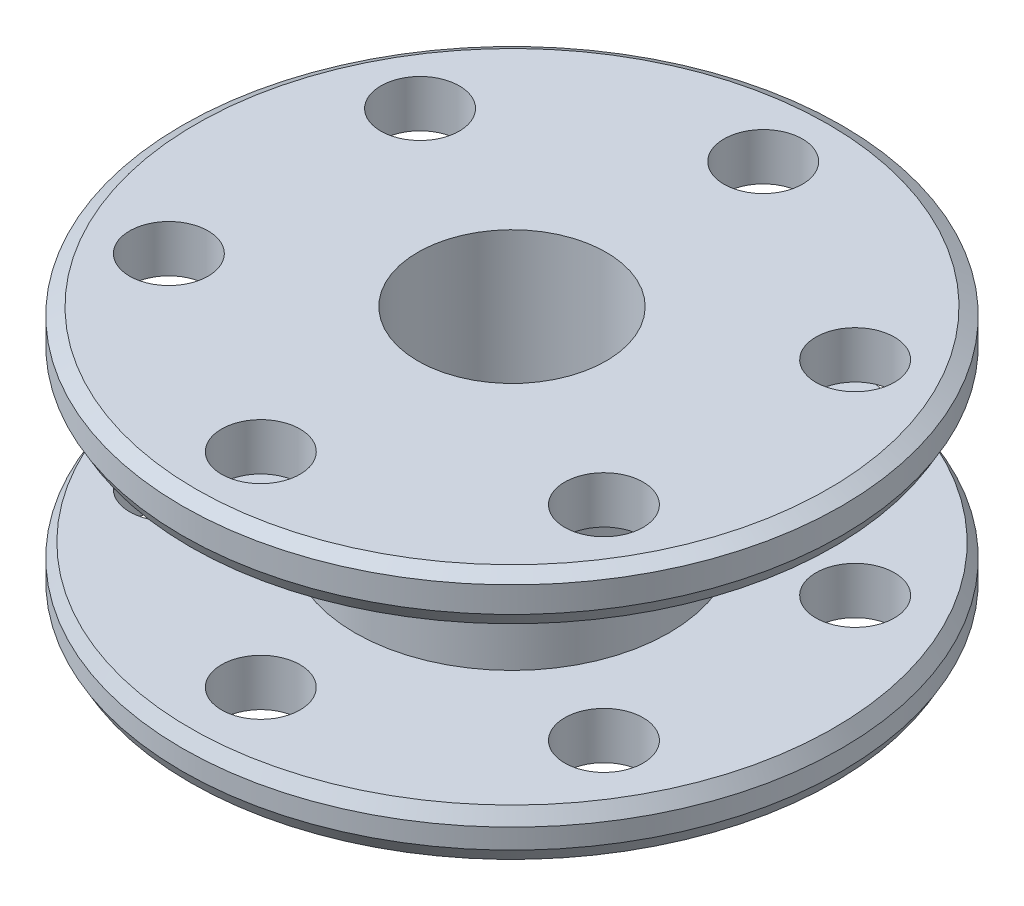
from build123d import *

# Parameters (mm, degrees)
SKETCH1_R             = 21
SKETCH1_R_2           = 6
SKETCH1_R_3           = 2.5
BOSS_EXTRUDE1_DEPTH   = 16
SKETCH2_W             = 19.188769359
SKETCH2_H             = 10
CHAMFER1_SIZE         = 0.5
CHAMFER1_SIZE2        = 0.866025404
CHAMFER1_PART_2_SIZE  = 0.5
CHAMFER1_PART_2_SIZE2 = 0.866025404
CHAMFER1_PART_3_SIZE  = 0.5
CHAMFER1_PART_3_SIZE2 = 0.866025404
CHAMFER1_PART_4_SIZE  = 0.5
CHAMFER1_PART_4_SIZE2 = 0.866025404


with BuildPart() as part:
    # Sketch1 → Boss-Extrude1 (new body)
    with BuildSketch(Plane(origin=(0, 0, 0), x_dir=(1, 0, 0), z_dir=(0, 1, 0))):
        Circle(SKETCH1_R)
        Circle(SKETCH1_R_2, mode=Mode.SUBTRACT)
        with Locations((0, 16)):
            Circle(SKETCH1_R_3, mode=Mode.SUBTRACT)
        with Locations((13.856406461, 8)):
            Circle(SKETCH1_R_3, mode=Mode.SUBTRACT)
        with Locations((13.856406461, -8)):
            Circle(SKETCH1_R_3, mode=Mode.SUBTRACT)
        with Locations((0, -16)):
            Circle(SKETCH1_R_3, mode=Mode.SUBTRACT)
        with Locations((-13.856406461, -8)):
            Circle(SKETCH1_R_3, mode=Mode.SUBTRACT)
        with Locations((-13.856406461, 8)):
            Circle(SKETCH1_R_3, mode=Mode.SUBTRACT)
    extrude(amount=BOSS_EXTRUDE1_DEPTH)

    # Sketch2 → Cut-Revolve1 (revolve, cut)
    with BuildSketch(Plane(origin=(0, 0, 0), x_dir=(0, 0, -1), z_dir=(1, 0, 0))):
        with Locations((19.59438468, 8)):
            Rectangle(SKETCH2_W, SKETCH2_H)
    revolve(axis=Axis((0, 0, 0), (0, 1, 0)), mode=Mode.SUBTRACT)

    # Chamfer1
    chamfer1_edges = [part.edges().sort_by_distance(p)[0] for p in [
        (-21, 0, 0),
    ]]
    chamfer1_side = [part.faces().sort_by_distance(p)[0] for p in [
        (-20.406030304, 0, 0),
    ]]
    chamfer(chamfer1_edges, length=CHAMFER1_SIZE, length2=CHAMFER1_SIZE2, reference=chamfer1_side[0])

    # Chamfer1 part 2
    chamfer1_part_2_edges = [part.edges().sort_by_distance(p)[0] for p in [
        (-21, 3, 0),
    ]]
    chamfer1_part_2_side = [part.faces().sort_by_distance(p)[0] for p in [
        (-20.406030304, 3, 0),
    ]]
    chamfer(chamfer1_part_2_edges, length=CHAMFER1_PART_2_SIZE, length2=CHAMFER1_PART_2_SIZE2, reference=chamfer1_part_2_side[0])

    # Chamfer1 part 3
    chamfer1_part_3_edges = [part.edges().sort_by_distance(p)[0] for p in [
        (-21, 13, 0),
    ]]
    chamfer1_part_3_side = [part.faces().sort_by_distance(p)[0] for p in [
        (-20.406030304, 13, 0),
    ]]
    chamfer(chamfer1_part_3_edges, length=CHAMFER1_PART_3_SIZE, length2=CHAMFER1_PART_3_SIZE2, reference=chamfer1_part_3_side[0])

    # Chamfer1 part 4
    chamfer1_part_4_edges = [part.edges().sort_by_distance(p)[0] for p in [
        (-21, 16, 0),
    ]]
    chamfer1_part_4_side = [part.faces().sort_by_distance(p)[0] for p in [
        (-21, 14.5, 0),
    ]]
    chamfer(chamfer1_part_4_edges, length=CHAMFER1_PART_4_SIZE, length2=CHAMFER1_PART_4_SIZE2, reference=chamfer1_part_4_side[0])


solid = part.part
